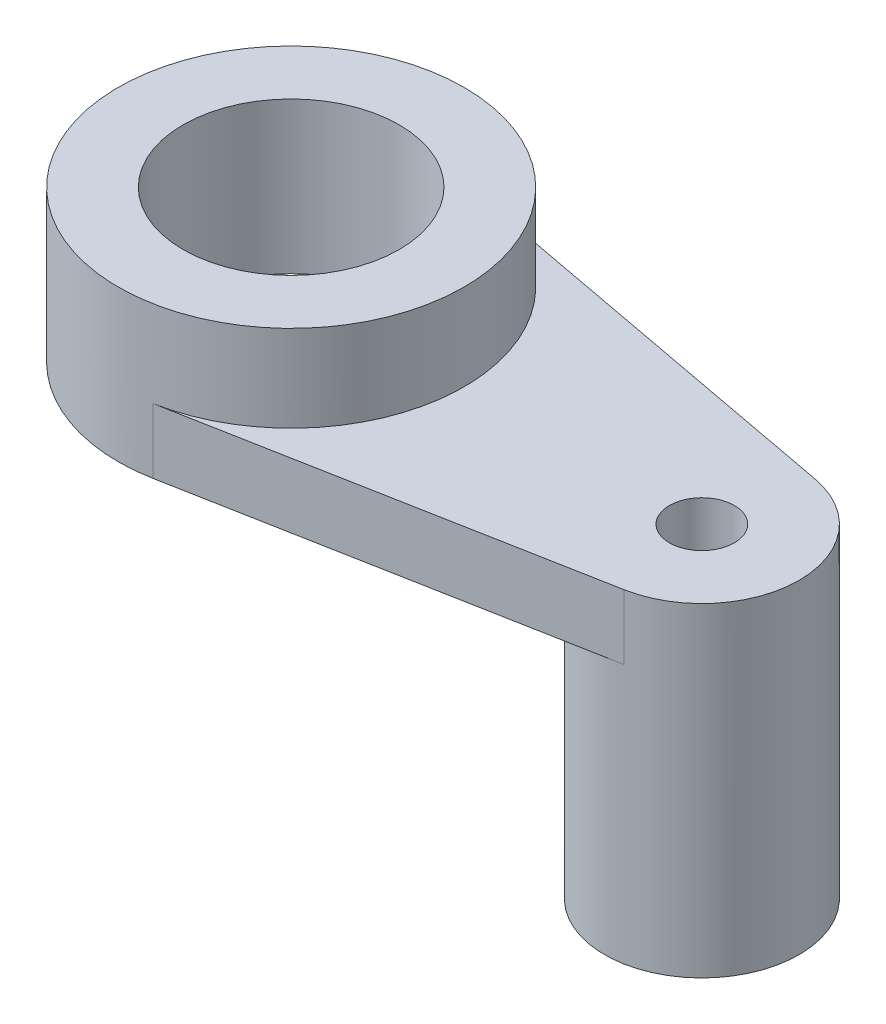
from build123d import *

# Parameters (mm, degrees)
BOSS_EXTRUDE1_DEPTH = 6
SKETCH2_R           = 3
CUT_EXTRUDE1_DEPTH  = 14
SKETCH3_R           = 16
SKETCH3_R_2         = 10
BOSS_EXTRUDE2_DEPTH = 14
SKETCH4_R           = 9
SKETCH4_R_2         = 3
BOSS_EXTRUDE3_DEPTH = 24


with BuildPart() as part:
    # Sketch1 → Boss-Extrude1 (new body)
    with BuildSketch(Plane(origin=(0, 0, 0), x_dir=(1, 0, 0), z_dir=(0, 1, 0))):
        with BuildLine():
            Line((2.947368, 15.726189), (39.657895, 8.845981))
            ThreePointArc((39.657895, 8.845981), (47, 0), (39.657895, -8.845981))
            Line((39.657895, -8.845981), (2.947368, -15.726189))
            ThreePointArc((2.947368, -15.726189), (16, 0), (2.947368, 15.726189))
        make_face()
    extrude(amount=BOSS_EXTRUDE1_DEPTH)

    # Sketch2 → Cut-Extrude1 (cut)
    with BuildSketch(Plane(origin=(0, 6, 0), x_dir=(1, 0, 0), z_dir=(0, 1, 0))):
        with Locations((38, 0)):
            Circle(SKETCH2_R)
    extrude(amount=-CUT_EXTRUDE1_DEPTH, mode=Mode.SUBTRACT)

    # Sketch3 → Boss-Extrude2 (add)
    with BuildSketch(Plane.XZ):
        Circle(SKETCH3_R)
        Circle(SKETCH3_R_2, mode=Mode.SUBTRACT)
    extrude(amount=-BOSS_EXTRUDE2_DEPTH)

    # Sketch4 → Boss-Extrude3 (add)
    with BuildSketch(Plane.XZ):
        with Locations((38, 0)):
            Circle(SKETCH4_R)
        with Locations((38, 0)):
            Circle(SKETCH4_R_2, mode=Mode.SUBTRACT)
    extrude(amount=BOSS_EXTRUDE3_DEPTH)


solid = part.part
